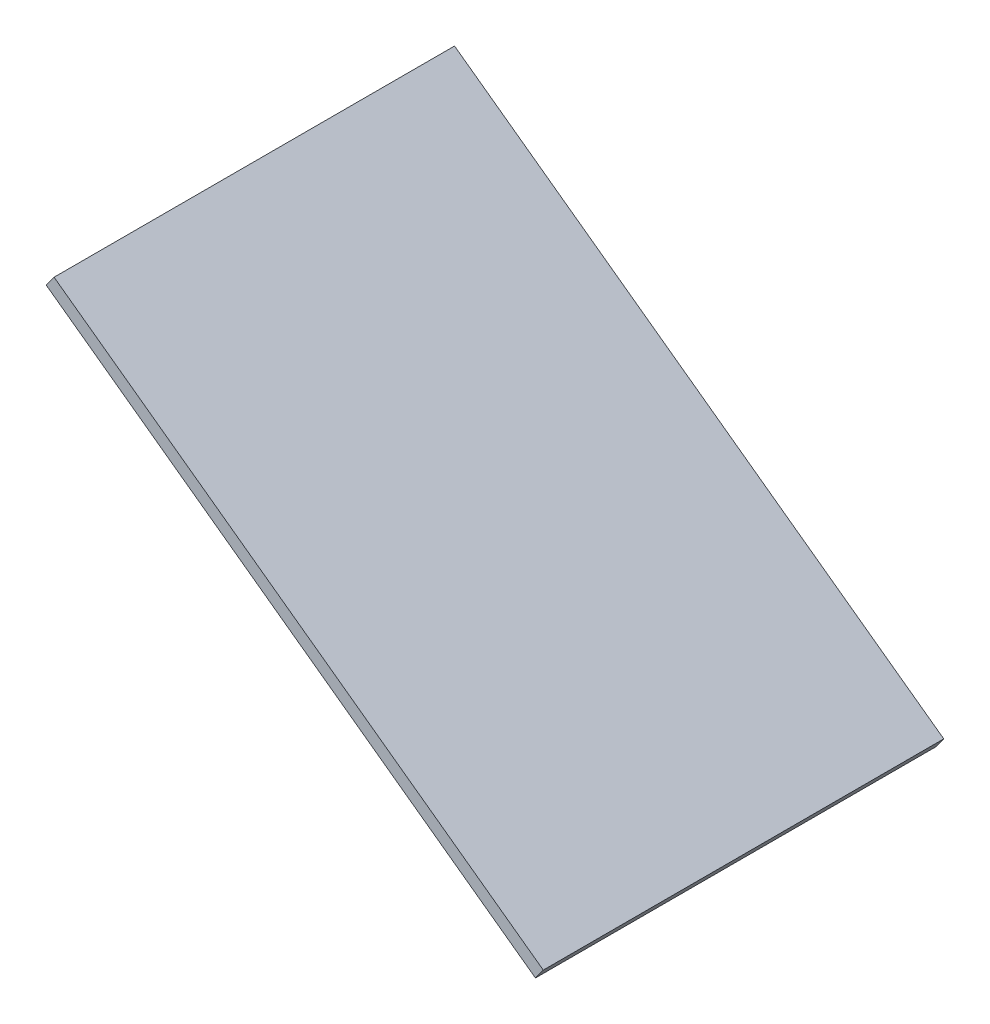
from build123d import *

# Parameters (mm, degrees)
SKETCH3_W           = 1053
SKETCH3_H           = 1590
BOSS_EXTRUDE1_DEPTH = 35
SKETCH5_W           = 1520
SKETCH5_H           = 983
CUT_EXTRUDE2_DEPTH  = 32


with BuildPart() as part:
    # Sketch3 → Boss-Extrude1 (new body)
    with BuildSketch(Plane(origin=(0, 0, 0), x_dir=(0, 0, 1), z_dir=(-0.587785252, -0.809016994, 0))):
        with Locations((0, 795)):
            Rectangle(SKETCH3_W, SKETCH3_H)
    extrude(amount=-BOSS_EXTRUDE1_DEPTH)

    # Sketch5 → Cut-Extrude2 (cut)
    with BuildSketch(Plane(origin=(0, 0, 0), x_dir=(0.809016994, -0.587785252, 0), z_dir=(-0.587785252, -0.809016994, 0))):
        with Locations((-795, 0)):
            Rectangle(SKETCH5_W, SKETCH5_H)
    extrude(amount=-CUT_EXTRUDE2_DEPTH, mode=Mode.SUBTRACT)


solid = part.part
